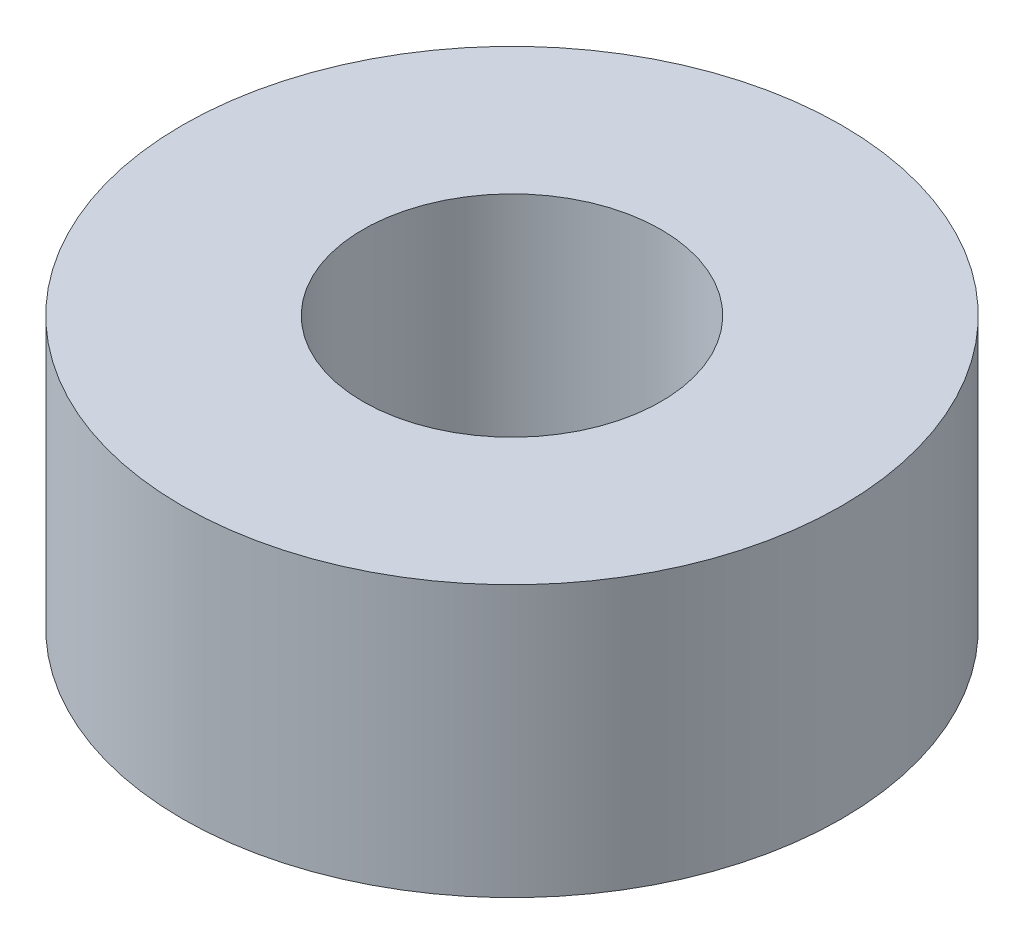
from build123d import *

# Parameters (mm, degrees)
SKETCH_1_R      = 3.65
SKETCH_1_R_2    = 1.65
EXTRUDE_1_DEPTH = 3


with BuildPart() as part:
    # 草图1 → 凸台-拉伸1 (new body)
    with BuildSketch(Plane(origin=(0, 0, 0), x_dir=(1, 0, 0), z_dir=(0, 1, 0))):
        Circle(SKETCH_1_R)
        Circle(SKETCH_1_R_2, mode=Mode.SUBTRACT)
    extrude(amount=EXTRUDE_1_DEPTH)


solid = part.part
